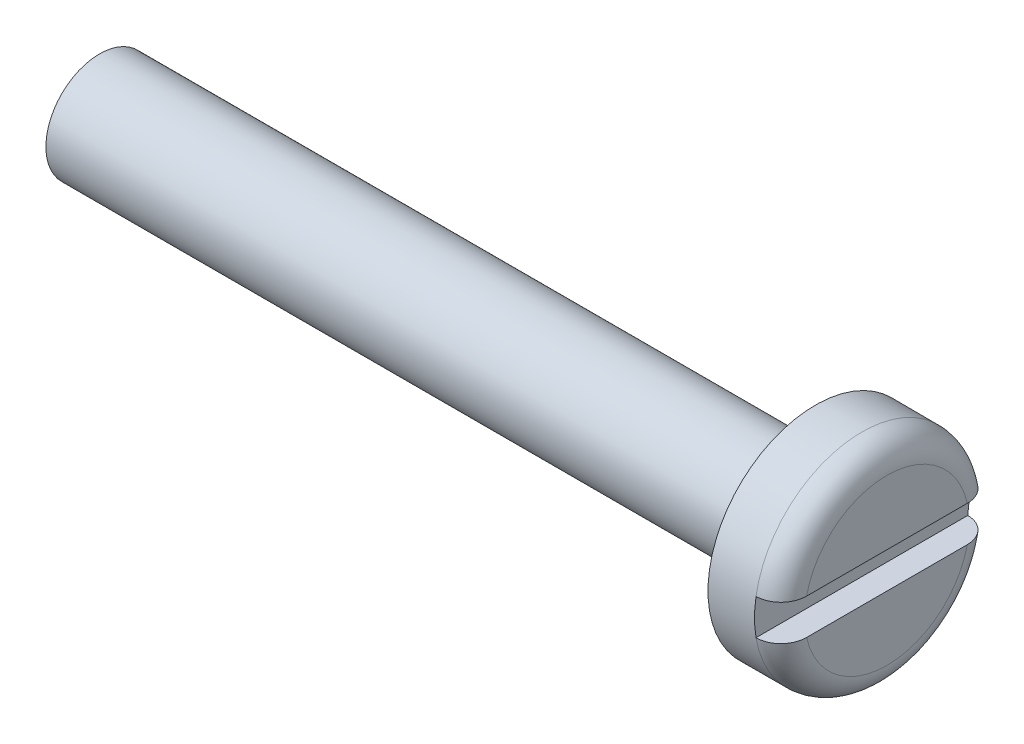
from build123d import *

# Parameters (mm, degrees)
SCHIZZO1_W                   = 20
SCHIZZO1_H                   = 1.5
SCHIZZO3_R                   = 3
ESTRUSIONE_ESTRUSIONE1_DEPTH = 2
SCHIZZO4_W                   = 7
SCHIZZO4_H                   = 1
TAGLIO_ESTRUSIONE1_DEPTH     = 0.7
RACCORDO1_R                  = 0.7


with BuildPart() as part:
    # Schizzo1 → Rivoluzione-Sottile1 (revolve)
    with BuildSketch(Plane.XY):
        with Locations((-10, -0.75)):
            Rectangle(SCHIZZO1_W, SCHIZZO1_H)
    revolve(axis=Axis((0, 0, 0), (-1, 0, 0)))

    # Schizzo3 → Estrusione-Estrusione1 (add)
    with BuildSketch(Plane(origin=(0, 0, 0), x_dir=(0, 0, -1), z_dir=(1, 0, 0))):
        Circle(SCHIZZO3_R)
    extrude(amount=ESTRUSIONE_ESTRUSIONE1_DEPTH)

    # Schizzo4 → Taglio-Estrusione1 (cut)
    with BuildSketch(Plane(origin=(2, 0, 0), x_dir=(0, 0, -1), z_dir=(1, 0, 0))):
        Rectangle(SCHIZZO4_W, SCHIZZO4_H)
    extrude(amount=-TAGLIO_ESTRUSIONE1_DEPTH, mode=Mode.SUBTRACT)

    # Raccordo1
    raccordo1_edges = [part.edges().sort_by_distance(p)[0] for p in [
        (2, -3, 0),
        (2, 3, 0),
    ]]
    fillet(raccordo1_edges, radius=RACCORDO1_R)


solid = part.part
